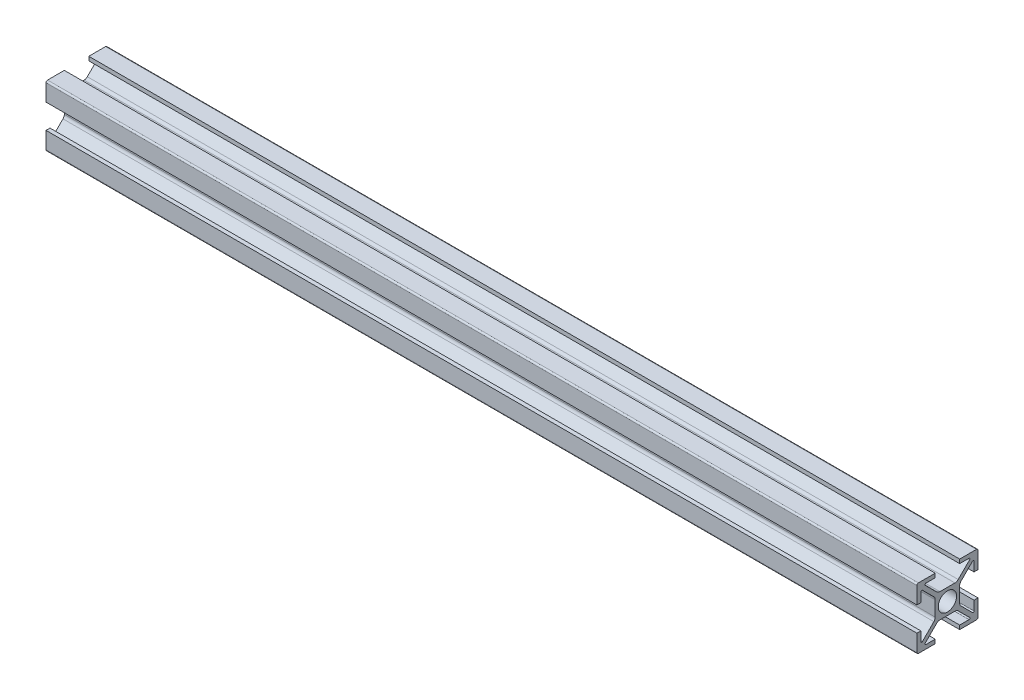
from build123d import *

# Parameters (mm, degrees)
SKETCH1_R                                   = 3
QUADRADO_PF20_01_PERFIL_2020_B_SICO_1_DEPTH = 285


with BuildPart() as part:
    # Sketch1 → Quadrado PF20-01 - PERFIL 2020 BÁSICO(1) (new body)
    with BuildSketch(Plane.YZ):
        with BuildLine():
            Line((8.187867966, -7.26862915), (4.439339828, -3.520101013))
            ThreePointArc((4.439339828, -3.520101013), (4.114180701, -3.033465989), (4, -2.459440841))
            Line((4, -2.459440841), (4, 2.459440841))
            ThreePointArc((4, 2.459440841), (4.114180701, 3.033465989), (4.439339828, 3.520101013))
            Line((4.439339828, 3.520101013), (8.187867966, 7.26862915))
            ThreePointArc((8.187867966, 7.26862915), (8.51480503, 7.333660975), (8.7, 7.056497116))
            Line((8.7, 7.056497116), (8.7, 4))
            Line((8.7, 4), (10, 4))
            Line((10, 4), (10, 9.5))
            ThreePointArc((10, 9.5), (9.853553391, 9.853553391), (9.5, 10))
            Line((9.5, 10), (4, 10))
            Line((4, 10), (4, 8.7))
            Line((4, 8.7), (7.056497116, 8.7))
            ThreePointArc((7.056497116, 8.7), (7.333660975, 8.51480503), (7.26862915, 8.187867966))
            Line((7.26862915, 8.187867966), (3.520101013, 4.439339828))
            ThreePointArc((3.520101013, 4.439339828), (3.033465989, 4.114180701), (2.459440841, 4))
            Line((2.459440841, 4), (-2.459440841, 4))
            ThreePointArc((-2.459440841, 4), (-3.033465989, 4.114180701), (-3.520101013, 4.439339828))
            Line((-3.520101013, 4.439339828), (-7.26862915, 8.187867966))
            ThreePointArc((-7.26862915, 8.187867966), (-7.333660975, 8.51480503), (-7.056497116, 8.7))
            Line((-7.056497116, 8.7), (-4, 8.7))
            Line((-4, 8.7), (-4, 10))
            Line((-4, 10), (-9.5, 10))
            ThreePointArc((-9.5, 10), (-9.853553391, 9.853553391), (-10, 9.5))
            Line((-10, 9.5), (-10, 4))
            Line((-10, 4), (-8.7, 4))
            Line((-8.7, 4), (-8.7, 7.056497116))
            ThreePointArc((-8.7, 7.056497116), (-8.51480503, 7.333660975), (-8.187867966, 7.26862915))
            Line((-8.187867966, 7.26862915), (-4.439339828, 3.520101013))
            ThreePointArc((-4.439339828, 3.520101013), (-4.114180701, 3.033465989), (-4, 2.459440841))
            Line((-4, 2.459440841), (-4, -2.459440841))
            ThreePointArc((-4, -2.459440841), (-4.114180701, -3.033465989), (-4.439339828, -3.520101013))
            Line((-4.439339828, -3.520101013), (-8.187867966, -7.26862915))
            ThreePointArc((-8.187867966, -7.26862915), (-8.51480503, -7.333660975), (-8.7, -7.056497116))
            Line((-8.7, -7.056497116), (-8.7, -4))
            Line((-8.7, -4), (-10, -4))
            Line((-10, -4), (-10, -9.5))
            ThreePointArc((-10, -9.5), (-9.853553391, -9.853553391), (-9.5, -10))
            Line((-9.5, -10), (-4, -10))
            Line((-4, -10), (-4, -8.7))
            Line((-4, -8.7), (-7.056497116, -8.7))
            ThreePointArc((-7.056497116, -8.7), (-7.333660975, -8.51480503), (-7.26862915, -8.187867966))
            Line((-7.26862915, -8.187867966), (-3.520101013, -4.439339828))
            ThreePointArc((-3.520101013, -4.439339828), (-3.033465989, -4.114180701), (-2.459440841, -4))
            Line((-2.459440841, -4), (2.459440841, -4))
            ThreePointArc((2.459440841, -4), (3.033465989, -4.114180701), (3.520101013, -4.439339828))
            Line((3.520101013, -4.439339828), (7.26862915, -8.187867966))
            ThreePointArc((7.26862915, -8.187867966), (7.333660975, -8.51480503), (7.056497116, -8.7))
            Line((7.056497116, -8.7), (4, -8.7))
            Line((4, -8.7), (4, -10))
            Line((4, -10), (9.5, -10))
            ThreePointArc((9.5, -10), (9.853553391, -9.853553391), (10, -9.5))
            Line((10, -9.5), (10, -4))
            Line((10, -4), (8.7, -4))
            Line((8.7, -4), (8.7, -7.056497116))
            ThreePointArc((8.7, -7.056497116), (8.51480503, -7.333660975), (8.187867966, -7.26862915))
        make_face()
        Circle(SKETCH1_R, mode=Mode.SUBTRACT)
    extrude(amount=QUADRADO_PF20_01_PERFIL_2020_B_SICO_1_DEPTH)


solid = part.part
